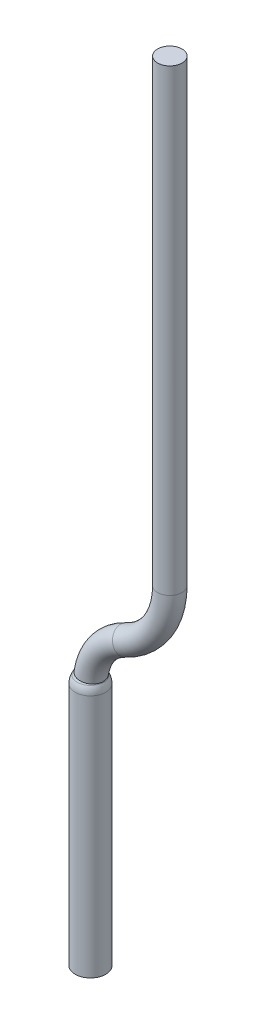
from build123d import *

# Parameters (mm, degrees)
SKETCH2_R = 0.8


with BuildPart() as part:
    # Sweep1: sweep along a path in Sketch1
    with BuildLine(Plane.XY) as sweep1_path:
        Line((-7.5, 54.2), (-7.5, 24.158431222))
        ThreePointArc((-7.5, 24.158431222), (-8.283629786, 21.471011972), (-10.388888889, 19.625969432))
        ThreePointArc((-10.388888889, 19.625969432), (-12.073096171, 18.1499354), (-12.7, 16))
        Line((-12.7, 16), (-12.7, 0))
    # Sketch2 → Sweep1 (sweep)
    with BuildSketch(Plane(origin=(0, 0, 0), x_dir=(1, 0, 0), z_dir=(0, 1, 0))):
        with Locations((-12.7, 0)):
            Circle(SKETCH2_R)
    sweep(path=sweep1_path.line)

    # Sketch3 → Revolve1 (revolve)
    with BuildSketch(Plane.XY):
        with BuildLine():
            Line((-12.7, 0), (-11.7, 0))
            Line((-11.7, 0), (-11.7, 16))
            ThreePointArc((-11.7, 16), (-11.734074174, 16.258819045), (-11.833974596, 16.5))
            Line((-11.833974596, 16.5), (-12.7, 18))
            Line((-12.7, 18), (-12.7, 0))
        make_face()
    revolve(axis=Axis((-12.7, 21.819423219, 0), (0, -1, 0)))


solid = part.part
